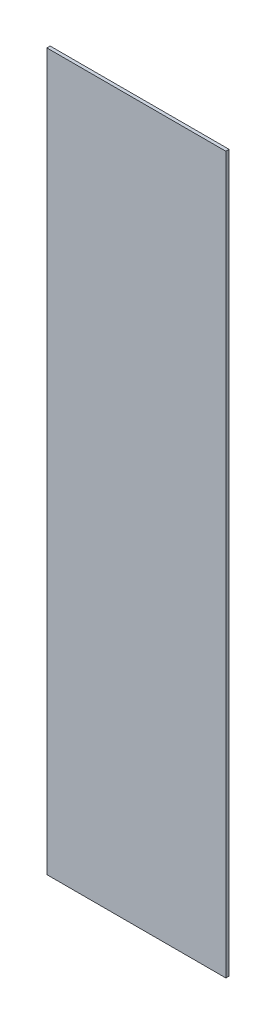
from build123d import *

# Parameters (mm, degrees)
SKETCH1_W           = 609.6
SKETCH1_H           = 2438.4
BOSS_EXTRUDE1_DEPTH = 11.1125


with BuildPart() as part:
    # Sketch1 → Boss-Extrude1 (new body)
    with BuildSketch(Plane.XY):
        with Locations((304.8, 1219.2)):
            Rectangle(SKETCH1_W, SKETCH1_H)
    extrude(amount=BOSS_EXTRUDE1_DEPTH)


solid = part.part
